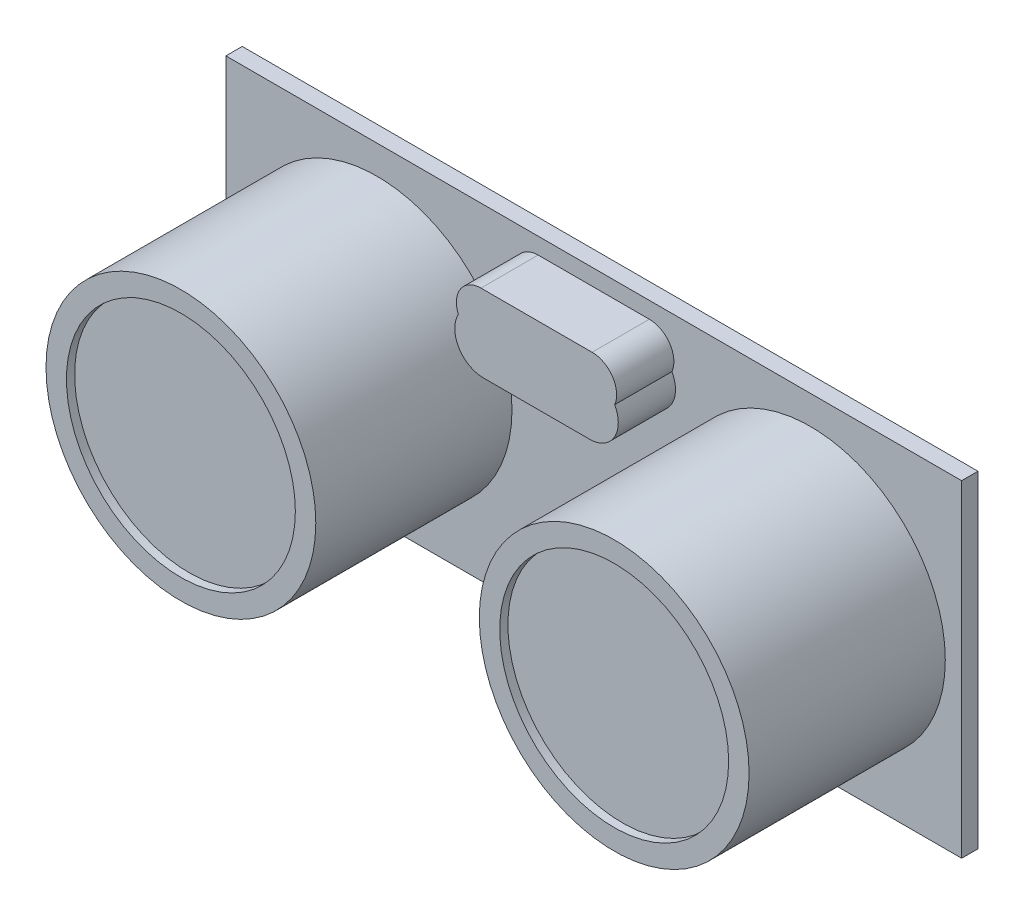
from build123d import *

# Parameters (mm, degrees)
ESBO_O1_W                = 45
ESBO_O1_H                = 20
RESSALTO_EXTRUS_O1_DEPTH = 1
ESBO_O2_R                = 8.25
RESSALTO_EXTRUS_O2_DEPTH = 12
ESBO_O3_R                = 7
CORTE_EXTRUS_O1_DEPTH    = 0.5
RESSALTO_EXTRUS_O5_DEPTH = 3.5
ESBO_O7_W                = 1.9
ESBO_O7_H                = 2
ESBO_O7_W_2              = 1.8
RESSALTO_EXTRUS_O6_DEPTH = 2
ESBO_O9_W                = 10
ESBO_O9_H                = 0.1
CORTE_EXTRUS_O2_DEPTH    = 2
ESBO_O10_W               = 1
ESBO_O10_H               = 1
RESSALTO_EXTRUS_O7_DEPTH = 2
ESBO_O11_W               = 1
ESBO_O11_H               = 1
ESBO_O11_H_2             = 0.967747288
RESSALTO_EXTRUS_O8_DEPTH = 4
RESSALTO_EXTRUS_O3_DEPTH = 3.5


with BuildPart() as part:
    # Esboço1 → Ressalto-extrusão1 (new body)
    with BuildSketch(Plane.XY):
        with Locations((22.5, 10)):
            Rectangle(ESBO_O1_W, ESBO_O1_H)
    extrude(amount=RESSALTO_EXTRUS_O1_DEPTH)

    # Esboço2 → Ressalto-extrusão2 (add)
    with BuildSketch(Plane.XY.offset(1)):
        with Locations((9.25, 10)):
            Circle(ESBO_O2_R)
        with Locations((35.75, 10)):
            Circle(ESBO_O2_R)
    extrude(amount=RESSALTO_EXTRUS_O2_DEPTH)

    # Esboço3 → Corte-extrusão1 (cut)
    with BuildSketch(Plane.XY.offset(13)):
        with Locations((9.25, 10)):
            Circle(ESBO_O3_R)
        with Locations((35.75, 10)):
            Circle(ESBO_O3_R)
    extrude(amount=-CORTE_EXTRUS_O1_DEPTH, mode=Mode.SUBTRACT)

    # Esboço6 → Ressalto-extrusão5 (add)
    with BuildSketch(Plane.XY.offset(1)):
        with BuildLine():
            Line((25.75, 17.816758405), (19.25, 17.816758405))
            ThreePointArc((19.25, 17.816758405), (17.5, 16.066758405), (19.25, 14.316758405))
            Line((19.25, 14.316758405), (25.75, 14.316758405))
            ThreePointArc((25.75, 14.316758405), (27.5, 16.066758405), (25.75, 17.816758405))
        make_face()
    extrude(amount=RESSALTO_EXTRUS_O5_DEPTH)

    # Esboço7 → Ressalto-extrusão6 (add)
    with BuildSketch(Plane(origin=(0, 0, 0), x_dir=(-1, 0, 0), z_dir=(0, 0, -1))):
        with Locations((-26.55, 1)):
            Rectangle(ESBO_O7_W, ESBO_O7_H)
        with Locations((-24.5, 1)):
            Rectangle(ESBO_O7_W_2, ESBO_O7_H)
        with Locations((-22.5, 1)):
            Rectangle(ESBO_O7_W_2, ESBO_O7_H)
        with Locations((-20.5, 1)):
            Rectangle(ESBO_O7_W_2, ESBO_O7_H)
        with Locations((-18.45, 1)):
            Rectangle(ESBO_O7_W, ESBO_O7_H)
    extrude(amount=RESSALTO_EXTRUS_O6_DEPTH)

    # Esboço9 → Corte-extrusão2 (cut)
    with BuildSketch(Plane(origin=(0, 0, -2), x_dir=(-1, 0, 0), z_dir=(0, 0, -1))):
        with Locations((-22.5, 0.05)):
            Rectangle(ESBO_O9_W, ESBO_O9_H)
    extrude(amount=-CORTE_EXTRUS_O2_DEPTH, mode=Mode.SUBTRACT)

    # Esboço10 → Ressalto-extrusão7 (add)
    with BuildSketch(Plane(origin=(0, 0, -2), x_dir=(-1, 0, 0), z_dir=(0, 0, -1))):
        with Locations((-24.5, 1.05)):
            Rectangle(ESBO_O10_W, ESBO_O10_H)
        with Locations((-26.55, 1.05)):
            Rectangle(ESBO_O10_W, ESBO_O10_H)
        with Locations((-22.472435469, 1.05)):
            Rectangle(ESBO_O10_W, ESBO_O10_H)
        with Locations((-20.46939422, 1.05)):
            Rectangle(ESBO_O10_W, ESBO_O10_H)
        with Locations((-18.471440092, 1.05)):
            Rectangle(ESBO_O10_W, ESBO_O10_H)
    extrude(amount=RESSALTO_EXTRUS_O7_DEPTH)

    # Esboço11 → Ressalto-extrusão8 (add)
    with BuildSketch(Plane.XZ.offset(-0.55)):
        with Locations((26.55, -3.5)):
            Rectangle(ESBO_O11_W, ESBO_O11_H)
        with Locations((24.5, -3.5)):
            Rectangle(ESBO_O11_W, ESBO_O11_H)
        with Locations((22.472435469, -3.516126356)):
            Rectangle(ESBO_O11_W, ESBO_O11_H_2)
        with Locations((20.46939422, -3.516126356)):
            Rectangle(ESBO_O11_W, ESBO_O11_H_2)
        with Locations((18.471440092, -3.516126356)):
            Rectangle(ESBO_O11_W, ESBO_O11_H_2)
    extrude(amount=RESSALTO_EXTRUS_O8_DEPTH)

    # Esboço4 → Ressalto-extrusão3 (add)
    with BuildSketch(Plane.XY.offset(1)):
        with BuildLine():
            ThreePointArc((20.566173289, 17.816758405), (20.042035666, 18.667291225), (19.1, 19))
            ThreePointArc((19.1, 19), (17.849334275, 18.328151704), (17.719012065, 16.914446994))
            ThreePointArc((17.719012065, 16.914446994), (18.361449222, 17.574398122), (19.25, 17.816758405))
            Line((19.25, 17.816758405), (20.566173289, 17.816758405))
        make_face()
        with BuildLine():
            ThreePointArc((20.6, 17.5), (20.591519348, 17.659279733), (20.566173289, 17.816758405))
            Line((20.566173289, 17.816758405), (19.25, 17.816758405))
            ThreePointArc((19.25, 17.816758405), (18.361449222, 17.574398122), (17.719012065, 16.914446994))
            ThreePointArc((17.719012065, 16.914446994), (18.271848296, 16.249334275), (19.1, 16))
            ThreePointArc((19.1, 16), (20.160660172, 16.439339828), (20.6, 17.5))
        make_face()
        with BuildLine():
            Line((25.9, 19), (19.1, 19))
            ThreePointArc((19.1, 19), (20.042035666, 18.667291225), (20.566173289, 17.816758405))
            Line((20.566173289, 17.816758405), (24.433826711, 17.816758405))
            ThreePointArc((24.433826711, 17.816758405), (24.957964334, 18.667291225), (25.9, 19))
        make_face()
        with BuildLine():
            ThreePointArc((27.4, 17.5), (26.960660172, 18.560660172), (25.9, 19))
            ThreePointArc((25.9, 19), (24.957964334, 18.667291225), (24.433826711, 17.816758405))
            Line((24.433826711, 17.816758405), (25.75, 17.816758405))
            ThreePointArc((25.75, 17.816758405), (26.638550778, 17.574398122), (27.280987935, 16.914446994))
            ThreePointArc((27.280987935, 16.914446994), (27.369945901, 17.201237471), (27.4, 17.5))
        make_face()
        with BuildLine():
            Line((25.75, 17.816758405), (24.433826711, 17.816758405))
            ThreePointArc((24.433826711, 17.816758405), (24.732708775, 16.557964334), (25.9, 16))
            ThreePointArc((25.9, 16), (26.728151704, 16.249334275), (27.280987935, 16.914446994))
            ThreePointArc((27.280987935, 16.914446994), (26.638550778, 17.574398122), (25.75, 17.816758405))
        make_face()
        with BuildLine():
            Line((24.433826711, 17.816758405), (20.566173289, 17.816758405))
            ThreePointArc((20.566173289, 17.816758405), (20.591519348, 17.659279733), (20.6, 17.5))
            ThreePointArc((20.6, 17.5), (20.160660172, 16.439339828), (19.1, 16))
            Line((19.1, 16), (25.9, 16))
            ThreePointArc((25.9, 16), (24.732708775, 16.557964334), (24.433826711, 17.816758405))
        make_face()
    extrude(amount=RESSALTO_EXTRUS_O3_DEPTH)


solid = part.part
